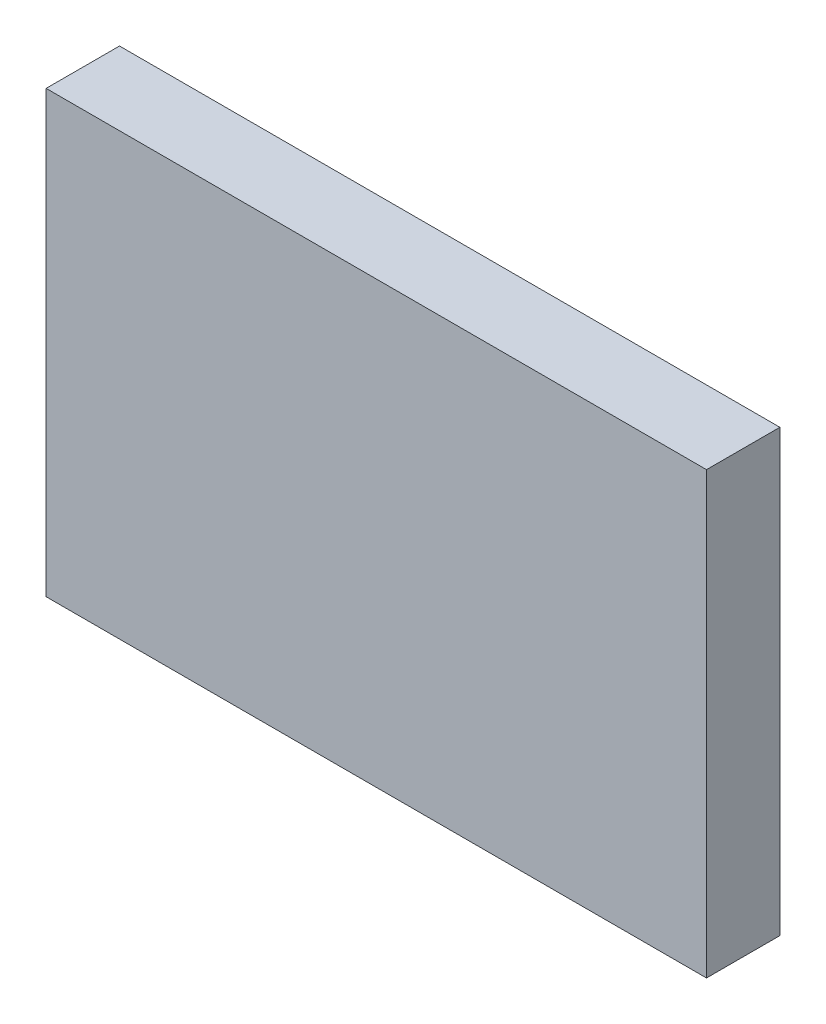
from build123d import *

# Parameters (mm, degrees)
SKETCH1_W           = 180
SKETCH1_H           = 120
BOSS_EXTRUDE1_DEPTH = 20


with BuildPart() as part:
    # Sketch1 → Boss-Extrude1 (new body)
    with BuildSketch(Plane.XY):
        with Locations((90, 60)):
            Rectangle(SKETCH1_W, SKETCH1_H)
    extrude(amount=BOSS_EXTRUDE1_DEPTH)


solid = part.part
